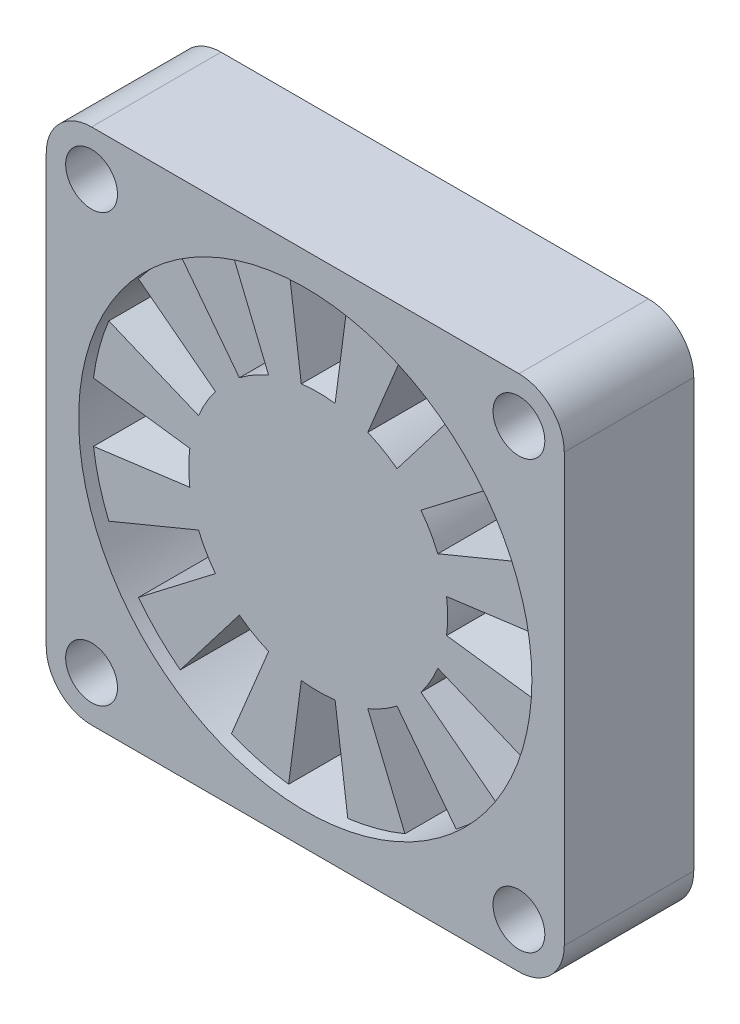
from build123d import *

# Parameters (mm, degrees)
SKETCH1_W           = 40
SKETCH1_H           = 40
BOSS_EXTRUDE1_DEPTH = 10
FILLET1_R           = 3.5
SKETCH2_R           = 2
CUT_EXTRUDE1_DEPTH  = 11
CUT_EXTRUDE2_DEPTH  = 11
CIRPATTERN1_COUNT   = 12
SKETCH6_R           = 17.5
CUT_EXTRUDE3_DEPTH  = 1


with BuildPart() as part:
    # Sketch1 → Boss-Extrude1 (new body)
    with BuildSketch(Plane.XY):
        Rectangle(SKETCH1_W, SKETCH1_H)
    extrude(amount=BOSS_EXTRUDE1_DEPTH)

    # Fillet1
    fillet1_edges = [part.edges().sort_by_distance(p)[0] for p in [
        (20, -20, 5),
        (-20, -20, 5),
        (-20, 20, 5),
        (20, 20, 5),
    ]]
    fillet(fillet1_edges, radius=FILLET1_R)

    # Sketch2 → Cut-Extrude1 (cut, through all)
    with BuildSketch(Plane.XY.offset(10)):
        with Locations((16.5, -16.5)):
            Circle(SKETCH2_R)
        with Locations((16.5, 16.5)):
            Circle(SKETCH2_R)
        with Locations((-16.5, 16.5)):
            Circle(SKETCH2_R)
        with Locations((-16.5, -16.5)):
            Circle(SKETCH2_R)
    extrude(amount=-CUT_EXTRUDE1_DEPTH, mode=Mode.SUBTRACT)

    # Sketch5 → Cut-Extrude2 (cut, through all)
    with BuildSketch(Plane.XY.offset(10)):
        with BuildLine():
            Line((17.350285074, 2.284208364), (9.914448614, 1.305261922))
            ThreePointArc((9.914448614, 1.305261922), (9.978589232, 0.654031292), (10, 0))
            ThreePointArc((10, 0), (9.978589232, -0.654031292), (9.914448614, -1.305261922))
            Line((9.914448614, -1.305261922), (17.350285074, -2.284208364))
            ThreePointArc((17.350285074, -2.284208364), (17.462531157, -1.144554762), (17.5, 0))
            ThreePointArc((17.5, 0), (17.462531157, 1.144554762), (17.350285074, 2.284208364))
        make_face()
    cut_extrude2 = extrude(amount=-CUT_EXTRUDE2_DEPTH, mode=Mode.SUBTRACT)

    # CirPattern1: Cut-Extrude2 ×12 about axis
    cirpattern1_axis = Axis((0, 0, 0), (0, 0, 1))
    for i in range(1, CIRPATTERN1_COUNT):
        add(cut_extrude2.rotate(cirpattern1_axis, i * 360 / CIRPATTERN1_COUNT), mode=Mode.SUBTRACT)

    # Sketch6 → Cut-Extrude3 (cut)
    with BuildSketch(Plane.XY.offset(10)):
        Circle(SKETCH6_R)
    extrude(amount=-CUT_EXTRUDE3_DEPTH, mode=Mode.SUBTRACT)


solid = part.part
